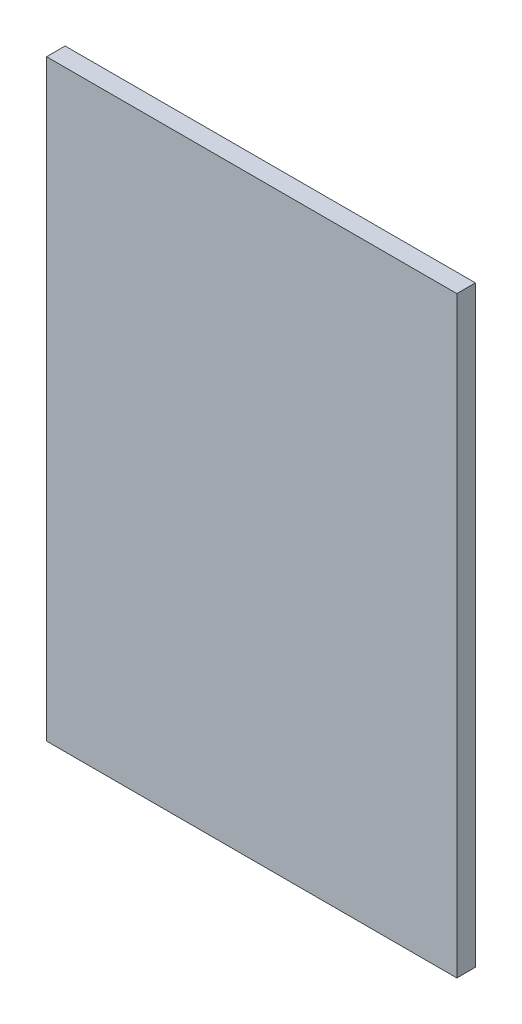
from build123d import *

# Parameters (mm, degrees)
SKETCH1_W           = 398
SKETCH1_H           = 575
BOSS_EXTRUDE1_DEPTH = 18


with BuildPart() as part:
    # Sketch1 → Boss-Extrude1 (new body)
    with BuildSketch(Plane.XY):
        Rectangle(SKETCH1_W, SKETCH1_H)
    extrude(amount=BOSS_EXTRUDE1_DEPTH)


solid = part.part
